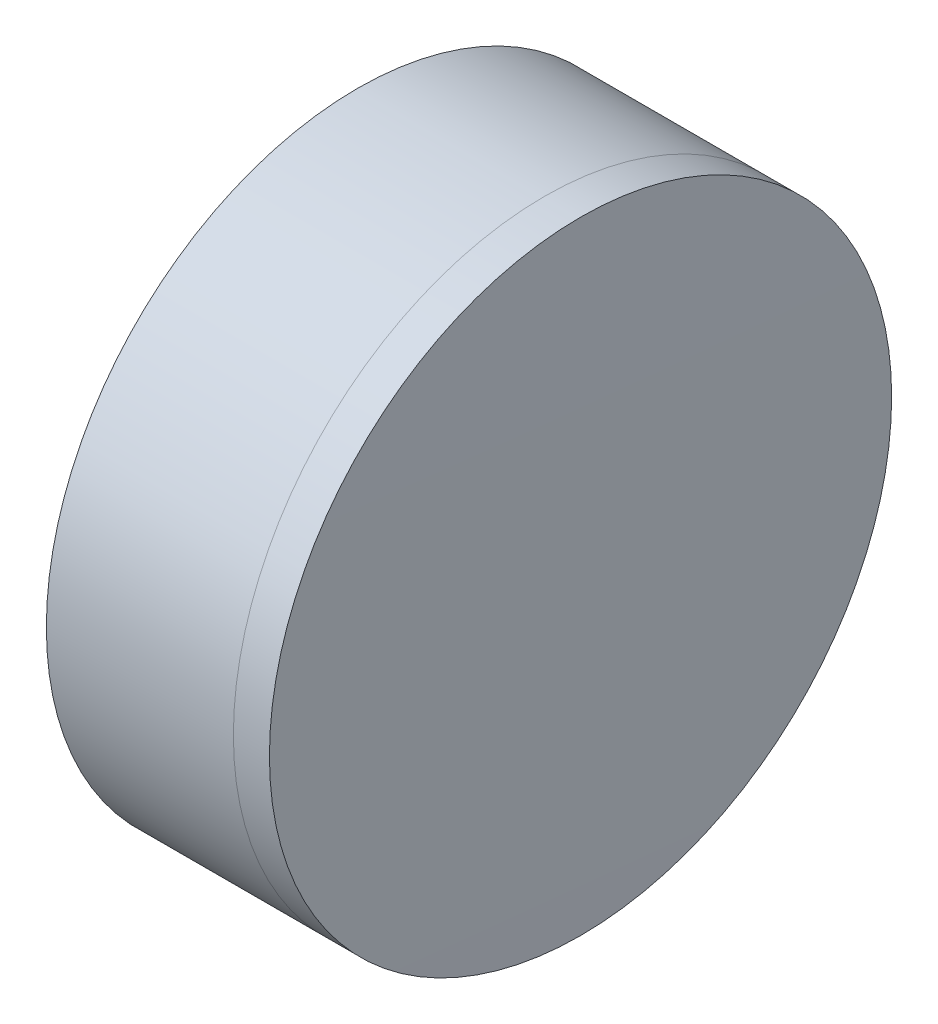
from build123d import *


with BuildPart() as part:
    # 草图1 one side → 旋转1 (revolve)
    with BuildSketch(Plane(origin=(0, 0, 0), x_dir=(1, 0, 0), z_dir=(0, 1, 0)), mode=Mode.PRIVATE) as revolve_1_sk:
        with BuildLine():
            Line((154.896811415, 12.7), (147.262101387, 12.7))
            ThreePointArc((147.262101387, 12.7), (149.625181899, 6.544423678), (150.428791315, 0))
            Line((150.428791315, 0), (152.428791315, 0))
            ThreePointArc((152.428791315, 0), (153.051514178, 6.46879284), (154.896811415, 12.7))
        make_face()
    revolve(revolve_1_sk.sketch.rotate(Axis((-185.274474051, 0, 0), (1, 0, 0)), 180), axis=Axis((-185.274474051, 0, 0), (1, 0, 0)))  # turned: the seam where the file's is


with BuildPart() as body_2:
    # 草图2 one side → 旋转3 (revolve)
    with BuildSketch(Plane(origin=(0, 0, 0), x_dir=(1, 0, 0), z_dir=(0, 1, 0)), mode=Mode.PRIVATE) as revolve_3_sk:
        with BuildLine():
            Line((156.368177382, 12.7), (154.896811415, 12.7))
            ThreePointArc((154.896811415, 12.7), (153.051514178, 6.46879284), (152.428791315, 0))
            Line((152.428791315, 0), (156.428791315, 0))
            ThreePointArc((156.428791315, 0), (156.413637745, 6.350072323), (156.368177382, 12.7))
        make_face()
    revolve(revolve_3_sk.sketch.rotate(Axis((147.262101387, 0, 0), (1, 0, 0)), 180), axis=Axis((147.262101387, 0, 0), (1, 0, 0)))  # turned: the seam where the file's is


solid = Compound([part.part, body_2.part])
